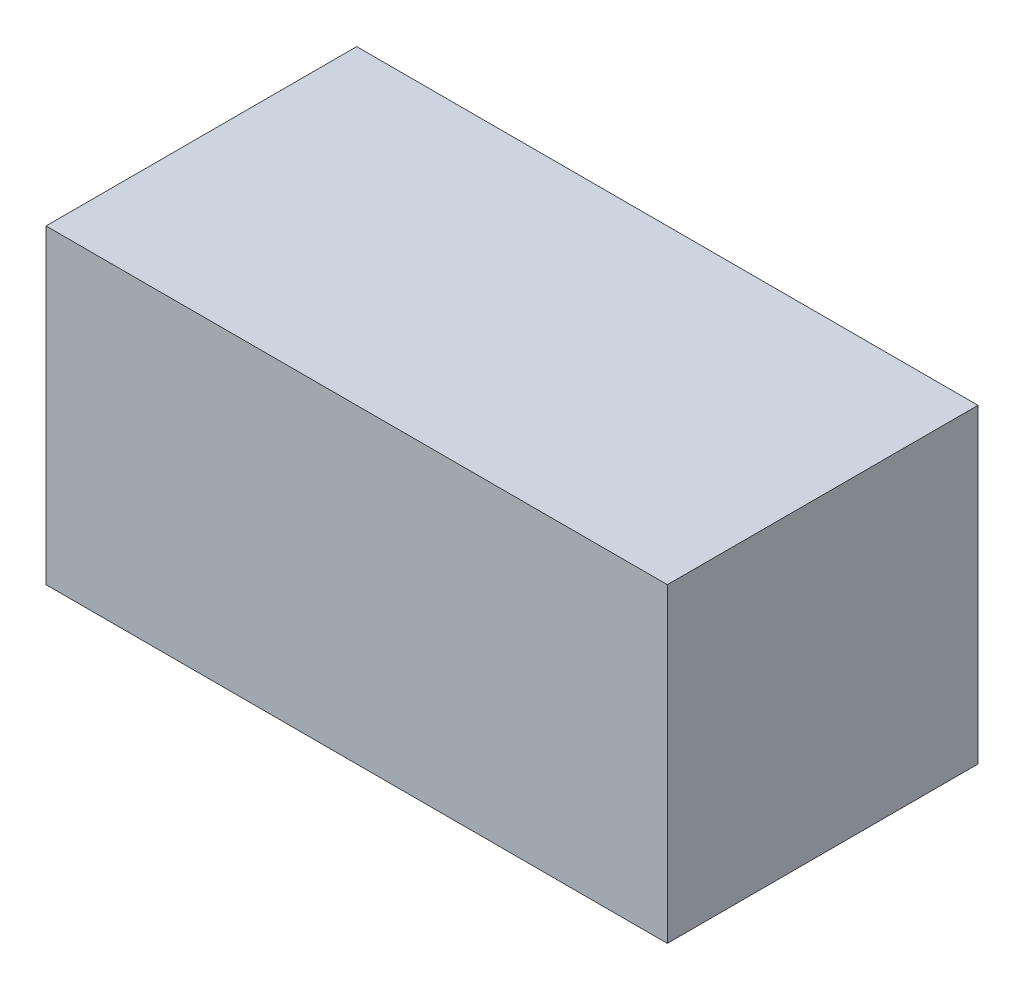
from build123d import *

# Parameters (mm, degrees)
SKETCH1_W           = 500
SKETCH1_H           = 250
BOSS_EXTRUDE1_DEPTH = 250


with BuildPart() as part:
    # Sketch1 → Boss-Extrude1 (new body)
    with BuildSketch(Plane(origin=(0, 0, 0), x_dir=(1, 0, 0), z_dir=(0, 1, 0))):
        Rectangle(SKETCH1_W, SKETCH1_H)
    extrude(amount=BOSS_EXTRUDE1_DEPTH)


solid = part.part
